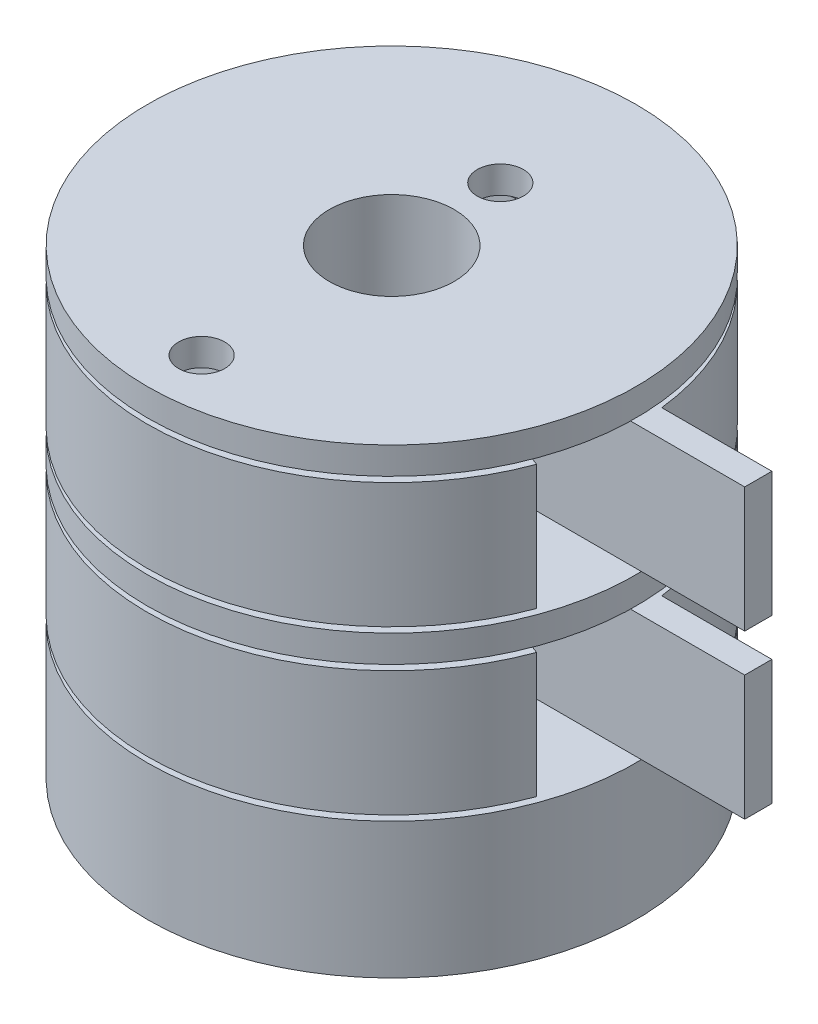
from build123d import *

# Parameters (mm, degrees)
ESBO_O3_R                  = 0.85
CORTE_EXTRUS_O1_DEPTH      = 11
CORTE_EXTRUS_O1_DEPTH_BACK = 8
ESBO_O4_R                  = 1.05
CORTE_EXTRUS_O2_DEPTH      = 10
CORTE_EXTRUS_O4_START      = -7
ESBO_O4_3_R                = 2
CORTE_EXTRUS_O4_DEPTH      = 3.0000001
CORTE_EXTRUS_O5_START      = -7
ESBO_O4_4_R                = 1.6
CORTE_EXTRUS_O5_DEPTH      = 3
RESSALTO_EXTRUS_O3_START   = 0.2
RESSALTO_EXTRUS_O3_DEPTH   = 4.6
RESSALTO_EXTRUS_O4_START   = -1.2
RESSALTO_EXTRUS_O4_DEPTH   = 4.6


with BuildPart() as part:
    # Esboço1 → Revolução1 (revolve)
    with BuildSketch(Plane.XY):
        Polygon((9, 3.5), (3.7, 3.5), (3.7, 8.5), (9, 8.5), (9, 9.5), (2.3, 9.5), (2.3, -7.5), (9, -7.5), (9, -2.5), (3.7, -2.5), (3.7, 2.5), (9, 2.5), align=None)
    revolve(axis=Axis((0, 0, 0), (0, 1, 0)))

    # Esboço3 → Corte-extrusão1 (cut, two sides)
    with BuildSketch(Plane.XZ.offset(-2.5)) as corte_extrus_o1_sk:
        with Locations((0, -4)):
            Circle(ESBO_O3_R)
        with Locations((0, 7)):
            Circle(ESBO_O3_R)
    extrude(amount=CORTE_EXTRUS_O1_DEPTH, mode=Mode.SUBTRACT)
    extrude(corte_extrus_o1_sk.sketch, amount=-CORTE_EXTRUS_O1_DEPTH_BACK, mode=Mode.SUBTRACT)

    # Esboço4 → Corte-extrusão2 (cut, through all)
    with BuildSketch(Plane(origin=(0, 0, 0), x_dir=(0, 0, -1), z_dir=(1, 0, 0))):
        with Locations((0, -5.1)):
            Circle(ESBO_O4_R)
    extrude(amount=-CORTE_EXTRUS_O2_DEPTH, mode=Mode.SUBTRACT)

    # Esboço4<3> → Corte-extrusão4 (cut, through all)
    with BuildSketch(Plane(origin=(0, 0, 0), x_dir=(0, 0, -1), z_dir=(1, 0, 0)).offset(CORTE_EXTRUS_O4_START)):
        with Locations((0, -5.1)):
            Circle(ESBO_O4_3_R)
    extrude(amount=-CORTE_EXTRUS_O4_DEPTH, mode=Mode.SUBTRACT)

    # Esboço4<4> → Corte-extrusão5 (cut)
    with BuildSketch(Plane(origin=(0, 0, 0), x_dir=(0, 0, -1), z_dir=(1, 0, 0)).offset(CORTE_EXTRUS_O5_START)):
        with Locations((0, -5.1)):
            Circle(ESBO_O4_4_R)
    extrude(amount=CORTE_EXTRUS_O5_DEPTH, mode=Mode.SUBTRACT)


with BuildPart() as body_2:
    # Esboço6 → Ressalto-extrusão3 (new body)
    with BuildSketch(Plane.XZ.offset(-2.5).offset(RESSALTO_EXTRUS_O3_START)):
        with BuildLine():
            Line((8.94427191, -1), (13, -1))
            Line((13, -1), (13, 0))
            Line((13, 0), (9, 0))
            Line((9, 0), (8.55, 0))
            Line((8.55, 0), (5.45, 0))
            Line((5.45, 0), (5, 0))
            ThreePointArc((5, 0), (-4.922451876, -0.877192982), (4.692212989, 1.727176097))
            Line((4.692212989, 1.727176097), (5.114512158, 1.882621946))
            ThreePointArc((5.114512158, 1.882621946), (-5.430744638, -0.457725546), (5.357471418, -1))
            Line((5.357471418, -1), (8.491319097, -1))
            ThreePointArc((8.491319097, -1), (-8.490807797, -1.004332095), (8.023684211, 2.953471126))
            Line((8.023684211, 2.953471126), (8.44598338, 3.108916974))
            ThreePointArc((8.44598338, 3.108916974), (-8.934542206, -1.083492301), (8.94427191, -1))
        make_face()
    extrude(amount=RESSALTO_EXTRUS_O3_DEPTH)


with BuildPart() as body_3:
    # Esboço6<2> → Ressalto-extrusão4 (new body)
    with BuildSketch(Plane.XZ.offset(-2.5).offset(RESSALTO_EXTRUS_O4_START)):
        with BuildLine():
            Line((8.94427191, -1), (13, -1))
            Line((13, -1), (13, 0))
            Line((13, 0), (9, 0))
            Line((9, 0), (8.55, 0))
            Line((8.55, 0), (5.45, 0))
            Line((5.45, 0), (5, 0))
            ThreePointArc((5, 0), (-4.922451876, -0.877192982), (4.692212989, 1.727176097))
            Line((4.692212989, 1.727176097), (5.114512158, 1.882621946))
            ThreePointArc((5.114512158, 1.882621946), (-5.430744638, -0.457725546), (5.357471418, -1))
            Line((5.357471418, -1), (8.491319097, -1))
            ThreePointArc((8.491319097, -1), (-8.490807797, -1.004332095), (8.023684211, 2.953471126))
            Line((8.023684211, 2.953471126), (8.44598338, 3.108916974))
            ThreePointArc((8.44598338, 3.108916974), (-8.934542206, -1.083492301), (8.94427191, -1))
        make_face()
    extrude(amount=-RESSALTO_EXTRUS_O4_DEPTH)


solid = Compound([part.part, body_2.part, body_3.part])
